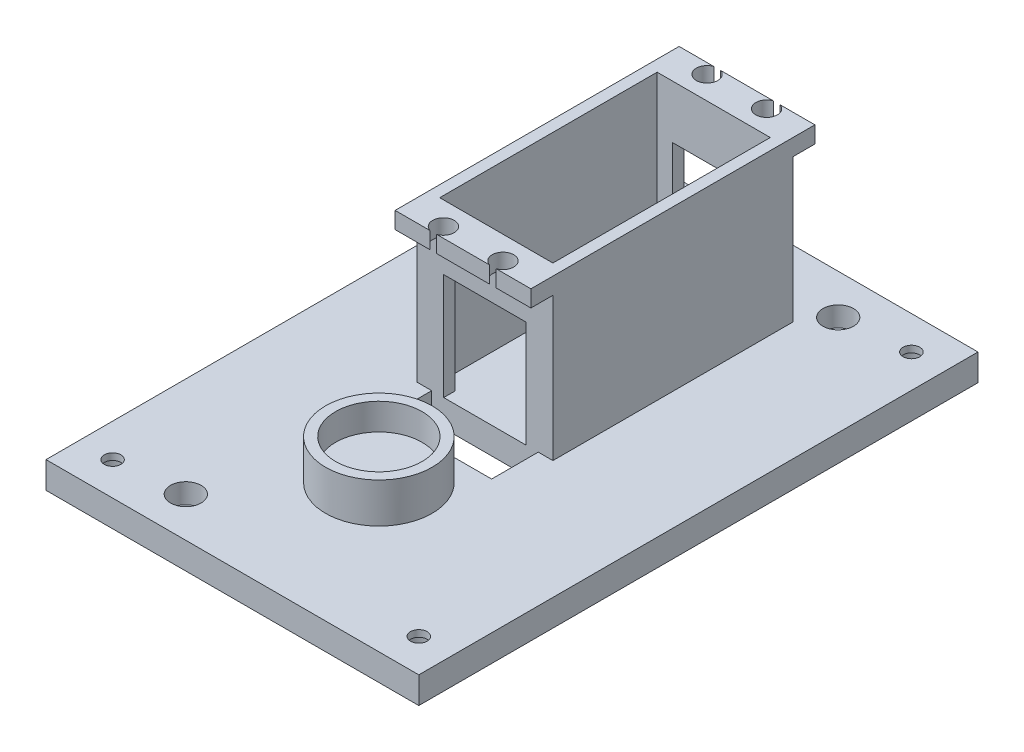
from build123d import *

# Parameters (mm, degrees)
SKETCH1_W           = 71.12
SKETCH1_H           = 106.68
BOSS_EXTRUDE1_DEPTH = 5.08
SKETCH3_W           = 25.908
SKETCH3_H           = 45.7962
SKETCH3_W_2         = 21.59
SKETCH3_H_2         = 41.4782
BOSS_EXTRUDE2_DEPTH = 27.305
SKETCH4_W           = 25.908
SKETCH4_H           = 54.1782
SKETCH4_W_2         = 21.59
SKETCH4_H_2         = 41.4782
BOSS_EXTRUDE3_DEPTH = 3.175
SKETCH5_R           = 2.04968221
CUT_EXTRUDE1_DEPTH  = 3.175
SKETCH7_W           = 15.748
SKETCH7_H           = 20.32
CUT_EXTRUDE3_DEPTH  = 45.7962
SKETCH8_R           = 10.16
BOSS_EXTRUDE4_DEPTH = 7.62
SKETCH9_R           = 8.255
CUT_EXTRUDE4_DEPTH  = 5.08
SKETCH10_W          = 20.32
SKETCH10_H          = 8.89
CUT_EXTRUDE5_DEPTH  = 6.08
SKETCH11_R          = 1.5875
CUT_EXTRUDE6_DEPTH  = 6.08
SKETCH15_R          = 2.921
CUT_EXTRUDE7_DEPTH  = 3.81
SKETCH16_R          = 2.921
CUT_EXTRUDE8_DEPTH  = 3.81
SKETCH17_R          = 1.5875
CUT_EXTRUDE9_DEPTH  = 36.56


with BuildPart() as part:
    # Sketch1 → Boss-Extrude1 (new body)
    with BuildSketch(Plane(origin=(56.401870569, 0, 2.613156724), x_dir=(1, 0, 0), z_dir=(0, 1, 0))):
        with Locations((-28.531301018, -3.803535099)):
            Rectangle(SKETCH1_W, SKETCH1_H)
    extrude(amount=BOSS_EXTRUDE1_DEPTH)

    # Sketch3 → Boss-Extrude2 (add)
    with BuildSketch(Plane(origin=(56.401870569, 5.08, 2.613156724), x_dir=(1, 0, 0), z_dir=(0, 1, 0))):
        with Locations((-28.531301018, 13.938364901)):
            Rectangle(SKETCH3_W, SKETCH3_H)
        with Locations((-28.531301018, 13.938364901)):
            Rectangle(SKETCH3_W_2, SKETCH3_H_2, mode=Mode.SUBTRACT)
    extrude(amount=BOSS_EXTRUDE2_DEPTH)

    # Sketch4 → Boss-Extrude3 (add)
    with BuildSketch(Plane(origin=(0, 32.385, 0), x_dir=(1, 0, 0), z_dir=(0, 1, 0))):
        with Locations((27.87056955, 11.325208176)):
            Rectangle(SKETCH4_W, SKETCH4_H)
        with Locations((27.87056955, 11.325208176)):
            Rectangle(SKETCH4_W_2, SKETCH4_H_2, mode=Mode.SUBTRACT)
    extrude(amount=BOSS_EXTRUDE3_DEPTH)

    # Sketch5 → Cut-Extrude1 (cut)
    with BuildSketch(Plane(origin=(0, 35.56, 0), x_dir=(1, 0, 0), z_dir=(0, 1, 0))):
        with Locations((22.19366955, 36.471208176)):
            Circle(SKETCH5_R)
        with Locations((33.54746955, 36.471208176)):
            Circle(SKETCH5_R)
        with Locations((22.19366955, -13.820791824)):
            Circle(SKETCH5_R)
        with Locations((33.54746955, -13.820791824)):
            Circle(SKETCH5_R)
    extrude(amount=-CUT_EXTRUDE1_DEPTH, mode=Mode.SUBTRACT)

    # Sketch7 → Cut-Extrude3 (cut)
    with BuildSketch(Plane(origin=(0, 0, -34.223308176), x_dir=(-1, 0, 0), z_dir=(0, 0, -1))):
        with Locations((-27.87056955, 15.24)):
            Rectangle(SKETCH7_W, SKETCH7_H)
    extrude(amount=-CUT_EXTRUDE3_DEPTH, mode=Mode.SUBTRACT)

    # Sketch8 → Boss-Extrude4 (add)
    with BuildSketch(Plane(origin=(0, 5.08, 0), x_dir=(1, 0, 0), z_dir=(0, 1, 0))):
        with Locations((27.87056955, -31.816691824)):
            Circle(SKETCH8_R)
    extrude(amount=BOSS_EXTRUDE4_DEPTH)

    # Sketch9 → Cut-Extrude4 (cut)
    with BuildSketch(Plane(origin=(0, 12.7, 0), x_dir=(1, 0, 0), z_dir=(0, 1, 0))):
        with Locations((27.87056955, -31.816691824)):
            Circle(SKETCH9_R)
    extrude(amount=-CUT_EXTRUDE4_DEPTH, mode=Mode.SUBTRACT)

    # Sketch10 → Cut-Extrude5 (cut, through all)
    with BuildSketch(Plane(origin=(0, 5.08, 0), x_dir=(1, 0, 0), z_dir=(0, 1, 0))):
        with Locations((27.87056955, -16.017891824)):
            Rectangle(SKETCH10_W, SKETCH10_H)
    extrude(amount=-CUT_EXTRUDE5_DEPTH, mode=Mode.SUBTRACT)

    # Sketch11 → Cut-Extrude6 (cut, through all)
    with BuildSketch(Plane(origin=(0, 5.08, 0), x_dir=(1, 0, 0), z_dir=(0, 1, 0))):
        with Locations((44.38056955, 39.303308176)):
            Circle(SKETCH11_R)
        with Locations((11.36056955, -52.136691824)):
            Circle(SKETCH11_R)
    extrude(amount=-CUT_EXTRUDE6_DEPTH, mode=Mode.SUBTRACT)

    # Sketch15 → Cut-Extrude7 (cut)
    with BuildSketch(Plane(origin=(0, 5.08, 0), x_dir=(1, 0, 0), z_dir=(0, 1, 0))):
        with Locations((11.36056955, -52.136691824)):
            Circle(SKETCH15_R)
        with Locations((44.38056955, 39.303308176)):
            Circle(SKETCH15_R)
    extrude(amount=-CUT_EXTRUDE7_DEPTH, mode=Mode.SUBTRACT)

    # Sketch16 → Cut-Extrude8 (cut)
    with BuildSketch(Plane.XZ):
        with Locations((-1.33943045, 53.406691824)):
            Circle(SKETCH16_R)
        with Locations((57.08056955, 53.406691824)):
            Circle(SKETCH16_R)
        with Locations((57.08056955, -40.573308176)):
            Circle(SKETCH16_R)
        with Locations((-1.33943045, -40.573308176)):
            Circle(SKETCH16_R)
    extrude(amount=-CUT_EXTRUDE8_DEPTH, mode=Mode.SUBTRACT)

    # Sketch17 → Cut-Extrude9 (cut, through all)
    with BuildSketch(Plane.XZ):
        with Locations((-1.33943045, 53.406691824)):
            Circle(SKETCH17_R)
        with Locations((57.08056955, 53.406691824)):
            Circle(SKETCH17_R)
        with Locations((57.08056955, -40.573308176)):
            Circle(SKETCH17_R)
        with Locations((-1.33943045, -40.573308176)):
            Circle(SKETCH17_R)
    extrude(amount=-CUT_EXTRUDE9_DEPTH, mode=Mode.SUBTRACT)


solid = part.part
